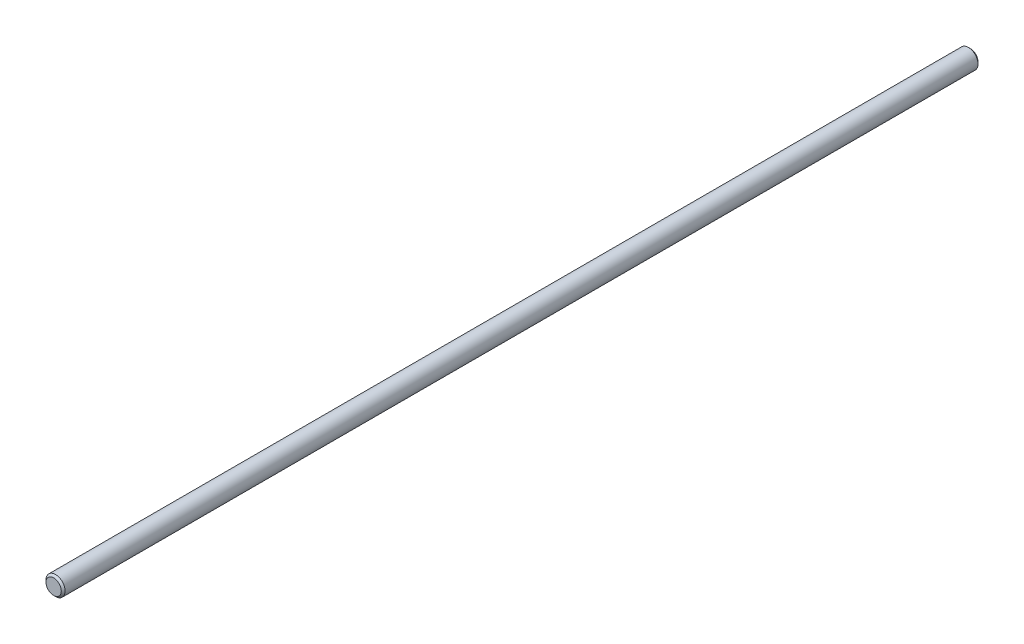
from build123d import *

# Parameters (mm, degrees)
SKETCH1_R      = 6.35
EXTRUDE1_DEPTH = 304.8
CHAMFER1_SIZE  = 1.27


with BuildPart() as part:
    # Sketch1 → Extrude1 (new body, symmetric)
    with BuildSketch(Plane.XY):
        Circle(SKETCH1_R)
    extrude(amount=EXTRUDE1_DEPTH, both=True)

    # Chamfer1
    chamfer1_edges = [part.edges().sort_by_distance(p)[0] for p in [
        (-6.35, 0, -304.8),
        (-6.35, 0, 304.8),
    ]]
    chamfer(chamfer1_edges, length=CHAMFER1_SIZE)


solid = part.part
